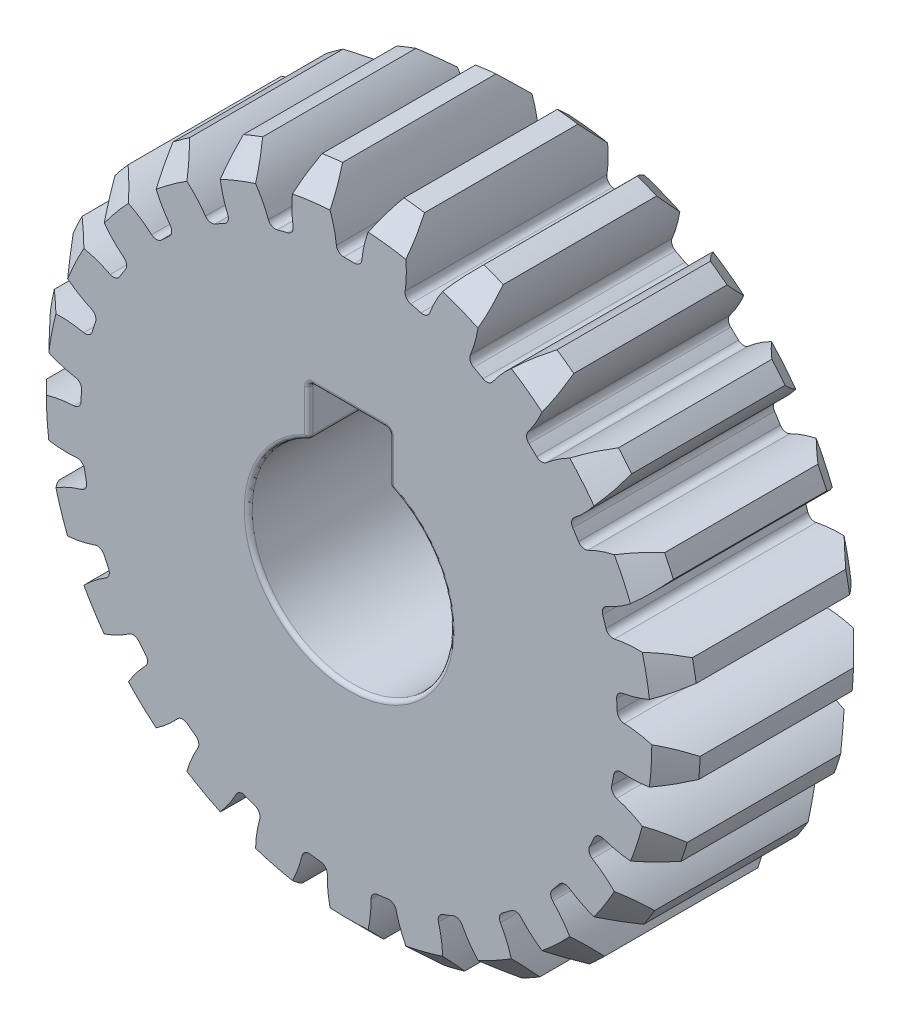
from build123d import *

# Parameters (mm, degrees)
SKETCH1_R                = 16.2
BOSS_EXTRUDE1_DEPTH      = 5
CUT_EXTRUDE1_DEPTH       = 6
FILLET1_R                = 0.36
CHAMFER1_SIZE            = 1.2
CIRPATTERN1_COUNT        = 25
FILLET1_OF_CIRPATTERN1_R = 0.36
CUT_EXTRUDE2_DEPTH       = 11.0000001
FILLET2_R                = 0.2


with BuildPart() as part:
    # Sketch1 → Boss-Extrude1 (new body, symmetric)
    with BuildSketch(Plane.XY):
        Circle(SKETCH1_R)
    extrude(amount=BOSS_EXTRUDE1_DEPTH, both=True)

    # Sketch2 → Cut-Extrude1 (cut, symmetric)
    with BuildSketch(Plane.XY):
        with BuildLine():
            ThreePointArc((1.520365166, 16.128499303), (0.872664083, 14.768576499), (0.605202341, 13.286223321))
            ThreePointArc((0.605202341, 13.286223321), (0, 13.3), (-0.605202341, 13.286223321))
            ThreePointArc((-0.605202341, 13.286223321), (-0.872664083, 14.768576499), (-1.520365166, 16.128499303))
            ThreePointArc((-1.520365166, 16.128499303), (0, 16.2), (1.520365166, 16.128499303))
        make_face()
    cut_extrude1 = extrude(amount=CUT_EXTRUDE1_DEPTH, both=True, mode=Mode.SUBTRACT)

    # Fillet1
    fillet1_edges = [part.edges().sort_by_distance(p)[0] for p in [
        (0.605202341, 13.286223321, 0),
        (-0.605202341, 13.286223321, 0),
    ]]
    fillet(fillet1_edges, radius=FILLET1_R)

    # Chamfer1
    chamfer1_edges = [part.edges().sort_by_distance(p)[0] for p in [
        (0, -16.2, -5),
        (0, -16.2, 5),
    ]]
    chamfer(chamfer1_edges, length=CHAMFER1_SIZE)

    # CirPattern1: Cut-Extrude1 ×25 about axis
    cirpattern1_axis = Axis((0, 0, 0), (0, 0, 1))
    for i in range(1, CIRPATTERN1_COUNT):
        add(cut_extrude1.rotate(cirpattern1_axis, i * 360 / CIRPATTERN1_COUNT), mode=Mode.SUBTRACT)

    # Fillet1 of CirPattern1
    fillet1_of_cirpattern1_edges = [part.edges().sort_by_distance(p)[0] for p in [
        (-2.717960582, 13.019319885, 0),
        (-3.890338175, 12.718304482, 0),
        (-5.870344046, 11.9343647, 0),
        (-6.931029754, 11.351247797, 0),
        (-8.653872203, 10.099529489, 0),
        (-9.536219243, 9.270950467, 0),
        (-10.893645744, 7.630103696, 0),
        (-11.542213005, 6.608125222, 0),
        (-12.448931458, 4.681250427, 0),
        (-12.822967074, 3.530087167, 0),
        (-13.222005025, 1.438256977, 0),
        (-13.298006963, 0.230240753, 0),
        (-13.164291388, -1.895107448, 0),
        (-12.937484168, -3.084072535, 0),
        (-12.27941691, -5.109395303, 0),
        (-11.764051662, -6.204602203, 0),
        (-10.622981506, -8.00264106, 0),
        (-9.851440524, -8.935273896, 0),
        (-8.299065105, -10.393051447, 0),
        (-7.319827148, -11.104509468, 0),
        (-5.453687922, -12.130428189, 0),
        (-4.328282111, -12.576007871, 0),
        (-2.26563547, -13.105605515, 0),
        (-1.064775191, -13.257309448, 0),
        (1.064775191, -13.257309448, 0),
        (2.26563547, -13.105605515, 0),
        (4.328282111, -12.576007871, 0),
        (5.453687922, -12.130428189, 0),
        (7.319827148, -11.104509468, 0),
        (8.299065105, -10.393051447, 0),
        (9.851440524, -8.935273896, 0),
        (10.622981506, -8.00264106, 0),
        (11.764051662, -6.204602203, 0),
        (12.27941691, -5.109395303, 0),
        (12.937484168, -3.084072535, 0),
        (13.164291388, -1.895107448, 0),
        (13.298006963, 0.230240753, 0),
        (13.222005025, 1.438256977, 0),
        (12.822967074, 3.530087167, 0),
        (12.448931458, 4.681250427, 0),
        (11.542213005, 6.608125222, 0),
        (10.893645744, 7.630103696, 0),
        (9.536219243, 9.270950467, 0),
        (8.653872203, 10.099529489, 0),
        (6.931029754, 11.351247797, 0),
        (5.870344046, 11.9343647, 0),
        (3.890338175, 12.718304482, 0),
        (2.717960582, 13.019319885, 0),
    ]]
    fillet(fillet1_of_cirpattern1_edges, radius=FILLET1_OF_CIRPATTERN1_R)

    # Sketch3 → Cut-Extrude2 (cut, through all)
    with BuildSketch(Plane.XY.offset(5)):
        with BuildLine():
            Line((-2, 4.582575695), (-2, 7))
            Line((-2, 7), (2, 7))
            Line((2, 7), (2, 4.582575695))
            ThreePointArc((2, 4.582575695), (0, -5), (-2, 4.582575695))
        make_face()
    extrude(amount=-CUT_EXTRUDE2_DEPTH, mode=Mode.SUBTRACT)

    # Fillet2
    fillet2_edges = [part.edges().sort_by_distance(p)[0] for p in [
        (0, -5, -5),
        (2, 4.582575695, 0),
        (-2, 5.791287847, -5),
        (-2, 4.582575695, 0),
        (0, 7, -5),
        (-2, 7, 0),
        (2, 5.791287847, -5),
        (2, 7, 0),
        (0, -5, 5),
        (2, 5.791287847, 5),
        (0, 7, 5),
        (-2, 5.791287847, 5),
    ]]
    fillet(fillet2_edges, radius=FILLET2_R)


solid = part.part
